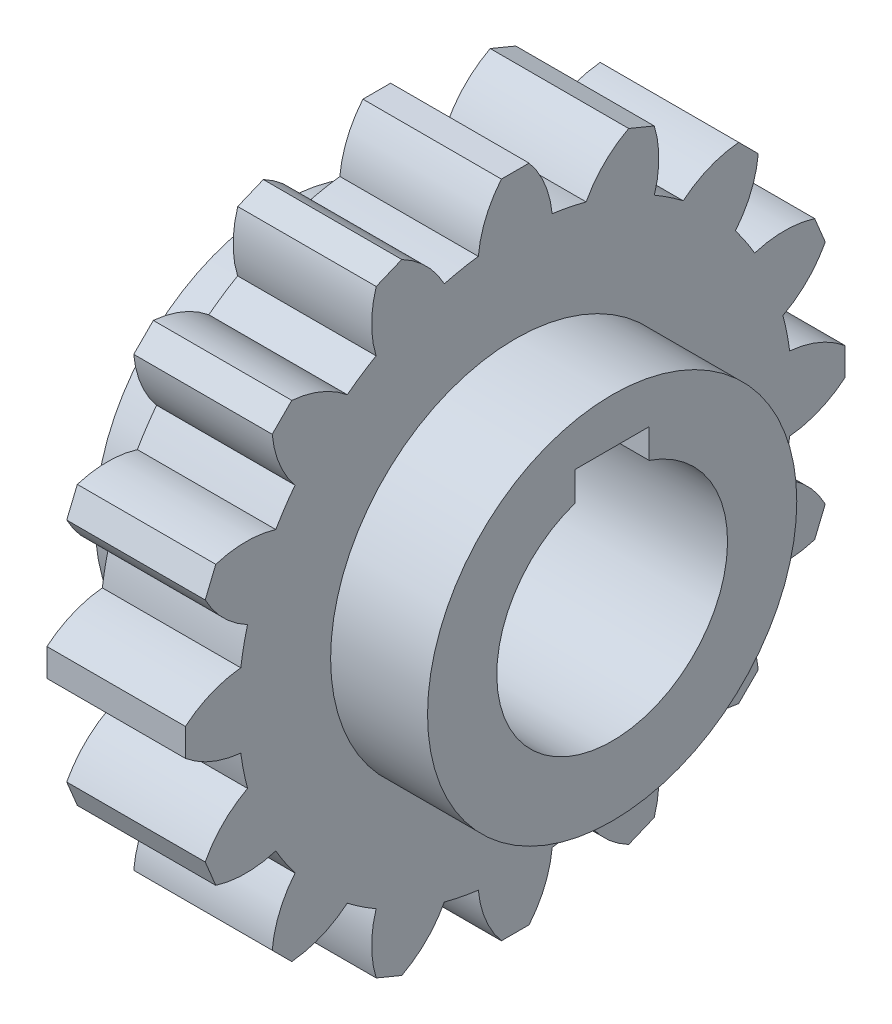
from build123d import *

# Parameters (mm, degrees)
SKETCH2_R           = 30
BOSS_EXTRUDE1_DEPTH = 7.5
BOSS_EXTRUDE2_DEPTH = 15
CIRPATTERN1_COUNT   = 16
SKETCH4_R           = 20
BOSS_EXTRUDE3_DEPTH = 18
CUT_EXTRUDE1_DEPTH  = 37


with BuildPart() as part:
    # Sketch2 → Boss-Extrude1 (new body, symmetric)
    with BuildSketch(Plane(origin=(0, 0, 0), x_dir=(0, 0, -1), z_dir=(1, 0, 0))):
        Circle(SKETCH2_R)
    extrude(amount=BOSS_EXTRUDE1_DEPTH, both=True)

    # Sketch3 → Boss-Extrude2 (add)
    with BuildSketch(Plane(origin=(7.5, 0, 0), x_dir=(0, 0, -1), z_dir=(1, 0, 0))):
        with BuildLine():
            Line((-1.5, 35.732137495), (1.5, 35.732137495))
            ThreePointArc((1.5, 35.732137495), (3.203300204, 32.92101258), (4, 29.732137495))
            ThreePointArc((4, 29.732137495), (0, 30), (-4, 29.732137495))
            ThreePointArc((-4, 29.732137495), (-3.203300204, 32.92101258), (-1.5, 35.732137495))
        make_face()
    boss_extrude2 = extrude(amount=-BOSS_EXTRUDE2_DEPTH)

    # CirPattern1: Boss-Extrude2 ×16 about axis
    cirpattern1_axis = Axis((0, 0, 0), (1, 0, 0))
    for i in range(1, CIRPATTERN1_COUNT):
        add(boss_extrude2.rotate(cirpattern1_axis, i * 360 / CIRPATTERN1_COUNT))

    # Sketch4 → Boss-Extrude3 (add, symmetric)
    with BuildSketch(Plane(origin=(0, 0, 0), x_dir=(0, 0, -1), z_dir=(1, 0, 0))):
        Circle(SKETCH4_R)
    extrude(amount=BOSS_EXTRUDE3_DEPTH, both=True)

    # Sketch5 → Cut-Extrude1 (cut, through all)
    with BuildSketch(Plane(origin=(18, 0, 0), x_dir=(0, 0, -1), z_dir=(1, 0, 0))):
        with BuildLine():
            Line((-4, 15), (4, 15))
            Line((4, 15), (4, 11.842719282))
            ThreePointArc((4, 11.842719282), (0, -12.5), (-4, 11.842719282))
            Line((-4, 11.842719282), (-4, 15))
        make_face()
    extrude(amount=-CUT_EXTRUDE1_DEPTH, mode=Mode.SUBTRACT)


solid = part.part
